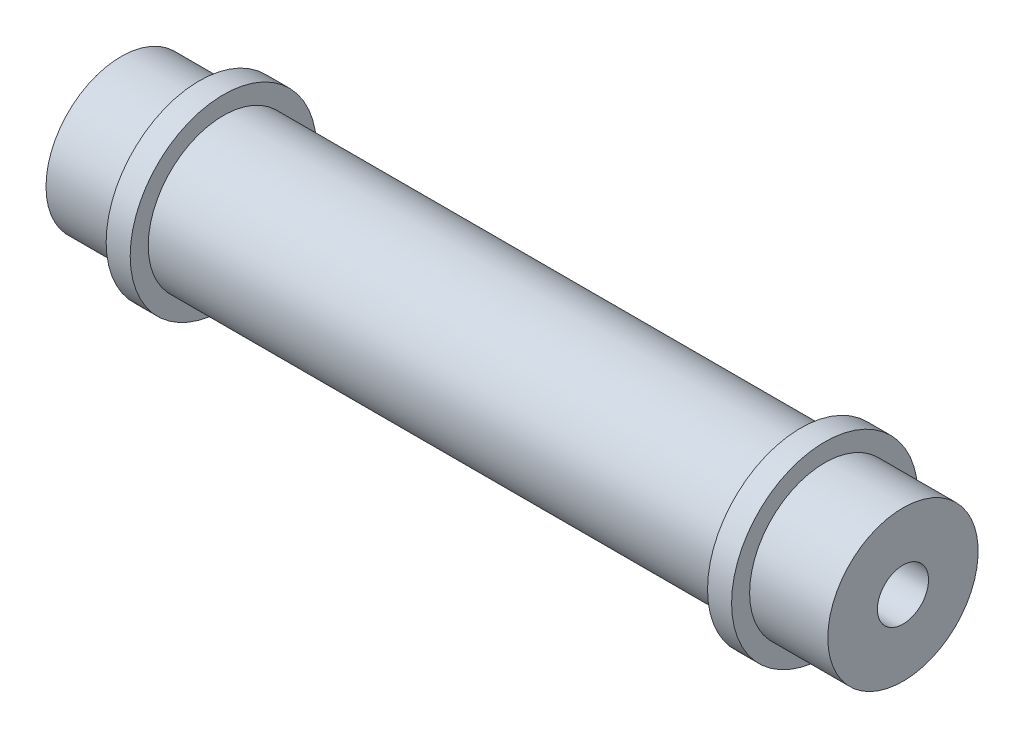
from build123d import *

# Parameters (mm, degrees)
HOLE_WIZARD_M101_D     = 8.5
HOLE_WIZARD_M101_DEPTH = 22.5
HOLE_WIZARD_M101_TIP   = 2.553657631


with BuildPart() as part:
    # Эскиз1 → Повернуть1 (revolve)
    with BuildSketch(Plane.XY):
        Polygon((0, 0), (0, 12.5), (48, 12.5), (48, 15.5), (52, 15.5), (52, 12.5), (65, 12.5), (65, 0), align=None)
    revolve(axis=Axis((-1000, 0, 0), (1, 0, 0)))

    # Отверстие обработанное метчиком M101
    with Locations(Plane(origin=(65, 0, 0), x_dir=(0, 0, -1), z_dir=(1, 0, 0))):
        with Locations((0, 0)):
            Hole(HOLE_WIZARD_M101_D / 2, depth=HOLE_WIZARD_M101_DEPTH)
            with Locations((0, 0, -(HOLE_WIZARD_M101_DEPTH + HOLE_WIZARD_M101_TIP / 2))):  # 118° drill point
                Cone(0, HOLE_WIZARD_M101_D / 2, HOLE_WIZARD_M101_TIP, mode=Mode.SUBTRACT)

    # Зеркальное отражение1: part across plane


with BuildPart() as part_1:
    add(part.part)
    add(part.part.mirror(Plane(origin=(0, 0, 0), x_dir=(0, 0, 1), z_dir=(1, 0, 0))))


solid = part_1.part
